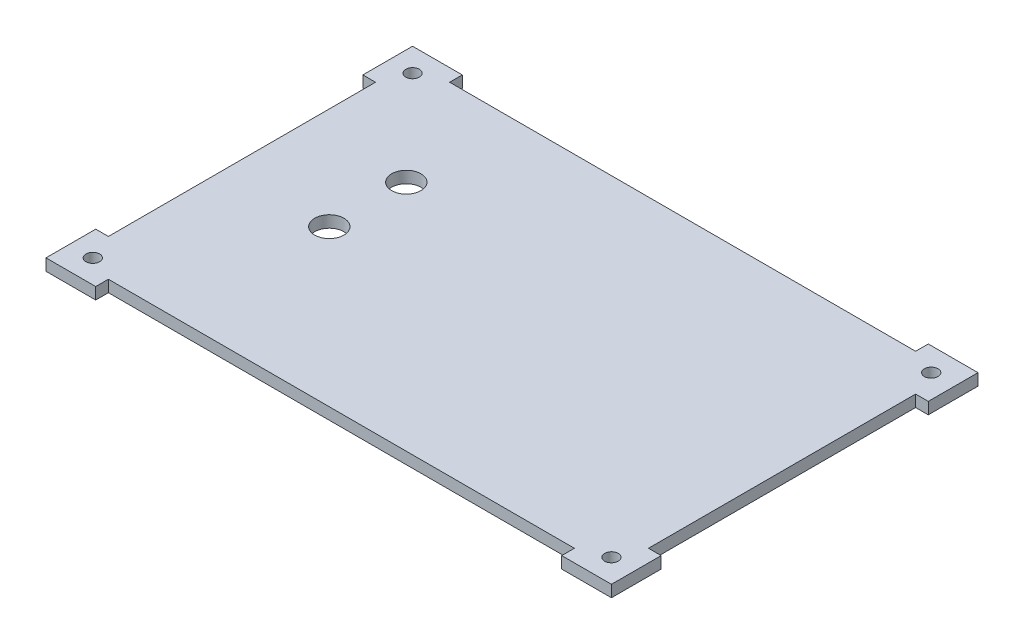
from build123d import *

# Parameters (mm, degrees)
SKETCH1_W           = 138.5
SKETCH1_H           = 87.5
BOSS_EXTRUDE1_DEPTH = 3
SKETCH2_R           = 1.75
CUT_EXTRUDE1_DEPTH  = 4
SKETCH3_W           = 9.5
SKETCH3_H           = 3.25
SKETCH3_W_2         = 3.25
SKETCH3_H_2         = 9.5
BOSS_EXTRUDE2_DEPTH = 3
SKETCH4_R           = 3.75
CUT_EXTRUDE2_DEPTH  = 4


with BuildPart() as part:
    # Sketch1 → Boss-Extrude1 (new body)
    with BuildSketch(Plane(origin=(0, 0, 0), x_dir=(1, 0, 0), z_dir=(0, 1, 0))):
        with Locations((69.25, -43.75)):
            Rectangle(SKETCH1_W, SKETCH1_H)
    extrude(amount=BOSS_EXTRUDE1_DEPTH)

    # Sketch2 → Cut-Extrude1 (cut, through all)
    with BuildSketch(Plane.XZ):
        with Locations((2.75, 84.75)):
            Circle(SKETCH2_R)
        with Locations((135.75, 84.75)):
            Circle(SKETCH2_R)
        with Locations((135.75, 2.75)):
            Circle(SKETCH2_R)
        with Locations((2.75, 2.75)):
            Circle(SKETCH2_R)
    extrude(amount=-CUT_EXTRUDE1_DEPTH, mode=Mode.SUBTRACT)

    # Sketch3 → Boss-Extrude2 (add, through all)
    with BuildSketch(Plane.XZ):
        Polygon((0, 90.75), (-3.25, 90.75), (-3.25, 78), (0, 78), (0, 87.5), align=None)
        with Locations((4.75, 89.125)):
            Rectangle(SKETCH3_W, SKETCH3_H)
        with Locations((-1.625, 4.75)):
            Rectangle(SKETCH3_W_2, SKETCH3_H_2)
        Polygon((9.5, 0), (0, 0), (-3.25, 0), (-3.25, -3.25), (9.5, -3.25), align=None)
        Polygon((138.5, 0), (129, 0), (129, -3.25), (141.75, -3.25), (141.75, 0), align=None)
        with Locations((140.125, 4.75)):
            Rectangle(SKETCH3_W_2, SKETCH3_H_2)
        with Locations((133.75, 89.125)):
            Rectangle(SKETCH3_W, SKETCH3_H)
        Polygon((138.5, 90.75), (138.5, 87.5), (138.5, 78), (141.75, 78), (141.75, 90.75), align=None)
    extrude(amount=-BOSS_EXTRUDE2_DEPTH)

    # Sketch4 → Cut-Extrude2 (cut, through all)
    with BuildSketch(Plane.XZ):
        with Locations((26.15, 47.5)):
            Circle(SKETCH4_R)
        with Locations((26.15, 27.75)):
            Circle(SKETCH4_R)
    extrude(amount=-CUT_EXTRUDE2_DEPTH, mode=Mode.SUBTRACT)


solid = part.part
